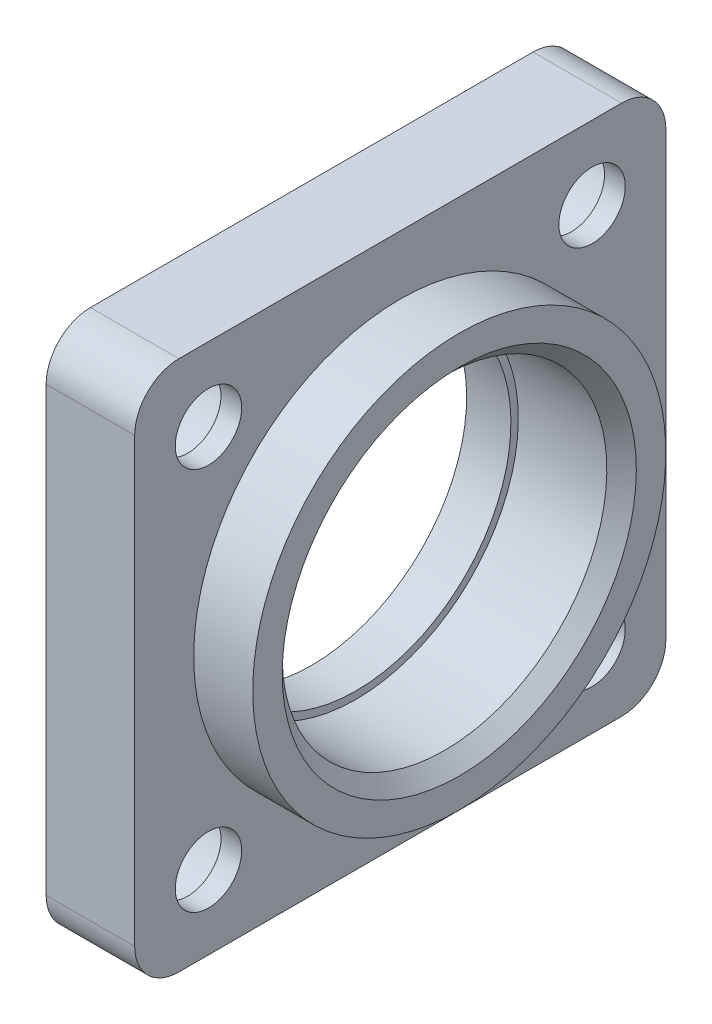
from build123d import *

# Parameters (mm, degrees)
EXTRUDE_1_DEPTH           = 6
FILLET_1_R                = 3
HOLE_WIZARD_2_D           = 4.5
HOLE_WIZARD_2_CBORE_D     = 8
HOLE_WIZARD_2_CBORE_DEPTH = 4.6
CHAMFER_1_SIZE            = 1


with BuildPart() as part:
    # 草图1 → 旋转1 (revolve)
    with BuildSketch(Plane.XY):
        Polygon((-6, 10.5), (-6, 18), (0, 18), (0, 14), (4, 14), (4, 11), (-3, 11), (-3, 10.5), align=None)
    revolve(axis=Axis((-10.541189269, 0, 0), (1, 0, 0)))

    # 草图5 → 凸台-拉伸1 (add)
    with BuildSketch(Plane.ZY.offset(6)):
        with BuildLine():
            ThreePointArc((-2.6e-08, 18), (12.727922052, 12.72792207), (18, 0))
            Line((18, 0), (18, 18))
            Line((18, 18), (-2.6e-08, 18))
        make_face()
        with BuildLine():
            Line((-18, 18), (-18, 3.1e-08))
            ThreePointArc((-18, 3.1e-08), (-12.72792206, 12.727922063), (-2.6e-08, 18))
            Line((-2.6e-08, 18), (-18, 18))
        make_face()
        with BuildLine():
            Line((-18, 3.1e-08), (-18, -18))
            Line((-18, -18), (0, -18))
            ThreePointArc((0, -18), (-12.727922072, -12.727922051), (-18, 3.1e-08))
        make_face()
        with BuildLine():
            ThreePointArc((18, 0), (12.727922061, -12.727922061), (0, -18))
            Line((0, -18), (18, -18))
            Line((18, -18), (18, 0))
        make_face()
    extrude(amount=-EXTRUDE_1_DEPTH)

    # 圆角1
    fillet_1_edges = [part.edges().sort_by_distance(p)[0] for p in [
        (-3, 18, 18),
        (-3, 18, -18),
        (-3, -18, -18),
        (-3, -18, 18),
    ]]
    fillet(fillet_1_edges, radius=FILLET_1_R)

    # 打孔尺寸(%根据)内六角圆柱头螺钉的类型2 (through all)
    with Locations(Plane.ZY.offset(6)):
        with Locations((-13, 13), (13, 13), (13, -13), (-13, -13)):
            CounterBoreHole(HOLE_WIZARD_2_D / 2, HOLE_WIZARD_2_CBORE_D / 2, HOLE_WIZARD_2_CBORE_DEPTH)

    # 倒角1
    chamfer_1_edges = [part.edges().sort_by_distance(p)[0] for p in [
        (4, -11, 0),
    ]]
    chamfer(chamfer_1_edges, length=CHAMFER_1_SIZE)


solid = part.part
